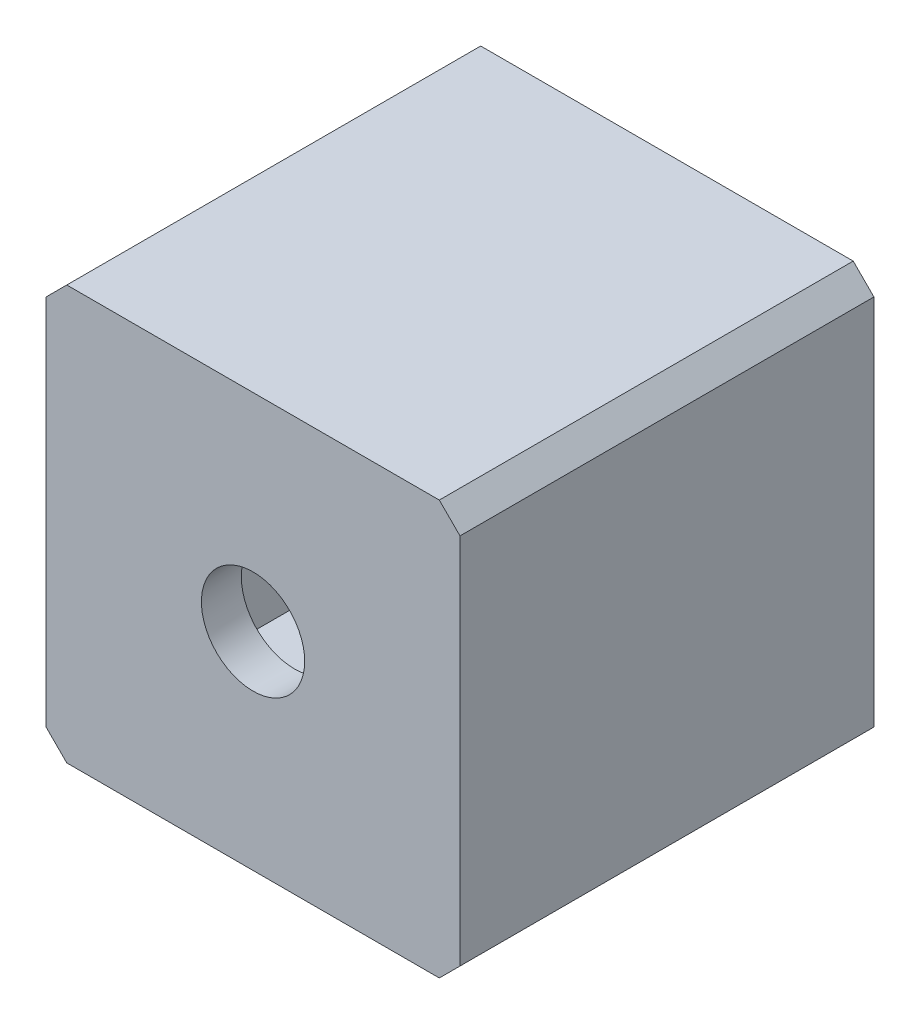
from build123d import *

# Parameters (mm, degrees)
ESQUISSE1_W             = 20
ESQUISSE1_H             = 20
BOSS_EXTRU_1_DEPTH      = 20
ENL_V_START             = -3
ESQUISSE2_R             = 2.6
ENL_V_MAT_EXTRU_1_DEPTH = 53.506491459
ENL_V_MAT_EXTRU_1_TAPER = 2
ESQUISSE3_W             = 16
ESQUISSE3_H             = 16
ENL_V_MAT_EXTRU_2_DEPTH = 18
CHANFREIN1_SIZE         = 1


with BuildPart() as part:
    # Esquisse1 → Boss.-Extru.1 (new body)
    with BuildSketch(Plane.XY):
        with Locations((-24.630410255, 19.182655502)):
            Rectangle(ESQUISSE1_W, ESQUISSE1_H)
    extrude(amount=BOSS_EXTRU_1_DEPTH)

    # Esquisse2 → Enlèv. mat.-Extru.1 (cut, through all)
    with BuildSketch(Plane.XY.offset(20).offset(ENL_V_START)):
        with Locations((-24.630410255, 19.182655502)):
            Circle(ESQUISSE2_R)
    extrude(amount=ENL_V_MAT_EXTRU_1_DEPTH, taper=ENL_V_MAT_EXTRU_1_TAPER, mode=Mode.SUBTRACT)

    # Esquisse3 → Enlèv. mat.-Extru.2 (cut)
    with BuildSketch(Plane(origin=(0, 0, 0), x_dir=(-1, 0, 0), z_dir=(0, 0, -1))):
        with Locations((24.630410255, 19.182655502)):
            Rectangle(ESQUISSE3_W, ESQUISSE3_H)
    extrude(amount=-ENL_V_MAT_EXTRU_2_DEPTH, mode=Mode.SUBTRACT)

    # Chanfrein1
    chanfrein1_edges = [part.edges().sort_by_distance(p)[0] for p in [
        (-34.630410255, 29.182655502, 10),
        (-14.630410255, 29.182655502, 10),
        (-14.630410255, 9.182655502, 10),
        (-34.630410255, 9.182655502, 10),
    ]]
    chamfer(chanfrein1_edges, length=CHANFREIN1_SIZE)


solid = part.part
